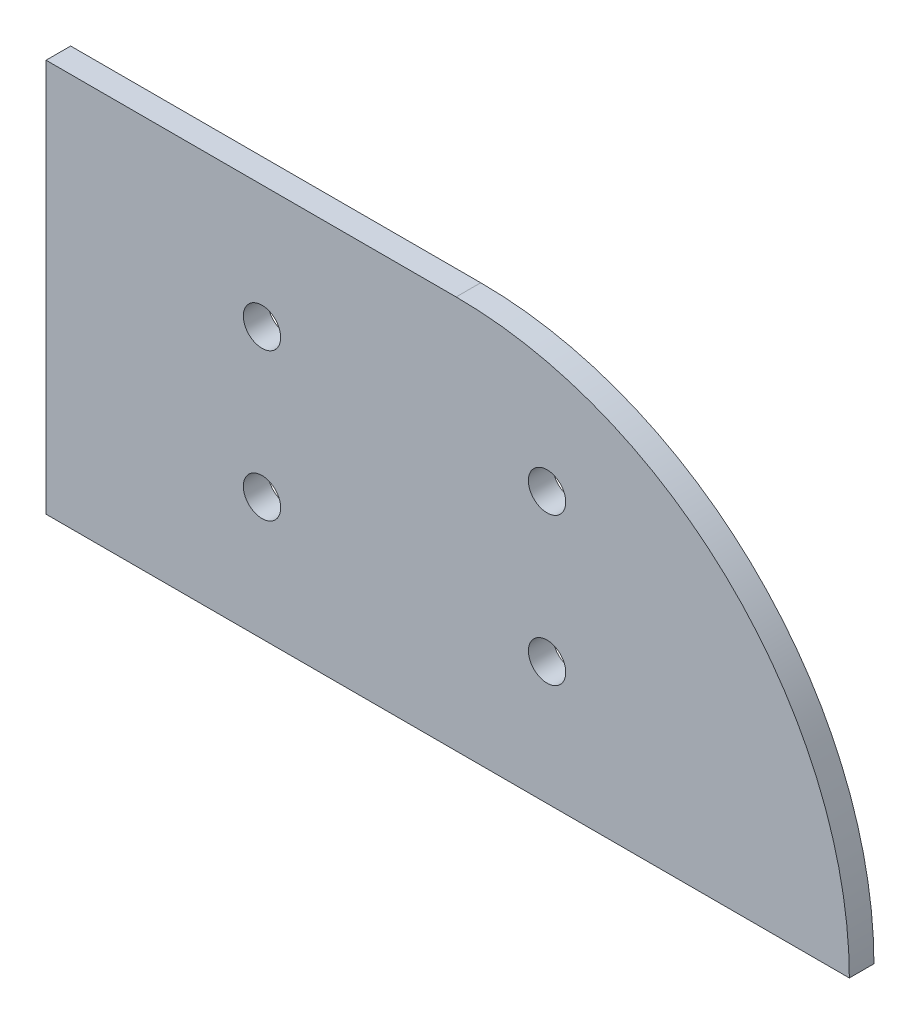
from build123d import *

# Parameters (mm, degrees)
BOSS_EXTRUDE1_DEPTH     = 3.175
SKETCH3_R               = 2.413
CUT_EXTRUDE1_DEPTH      = 1
CUT_EXTRUDE1_DEPTH_BACK = 4.175


with BuildPart() as part:
    # Sketch1 → Boss-Extrude1 (new body)
    with BuildSketch(Plane.XY):
        with BuildLine():
            Line((0, 50.8), (0, 0))
            Line((0, 0), (103.778975516, 0))
            ThreePointArc((103.778975516, 0), (88.9, 35.921024484), (52.978975516, 50.8))
            Line((52.978975516, 50.8), (0, 50.8))
        make_face()
    extrude(amount=BOSS_EXTRUDE1_DEPTH)

    # Sketch3 → Cut-Extrude1 (cut, two sides)
    with BuildSketch(Plane.XY.offset(3.175)) as cut_extrude1_sk:
        with Locations((64.726475516, 34.925)):
            Circle(SKETCH3_R)
        with Locations((27.896475516, 34.925)):
            Circle(SKETCH3_R)
        with Locations((27.896475516, 15.875)):
            Circle(SKETCH3_R)
        with Locations((64.726475516, 15.875)):
            Circle(SKETCH3_R)
    extrude(amount=CUT_EXTRUDE1_DEPTH, mode=Mode.SUBTRACT)
    extrude(cut_extrude1_sk.sketch, amount=-CUT_EXTRUDE1_DEPTH_BACK, mode=Mode.SUBTRACT)


solid = part.part
